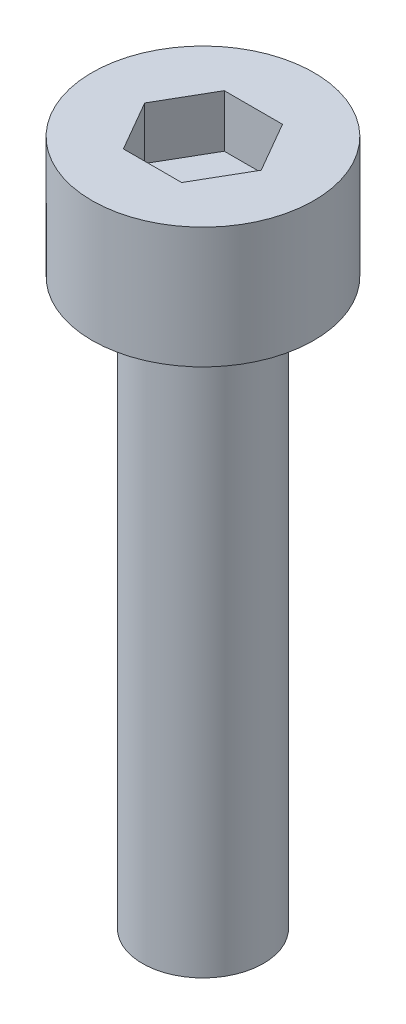
from build123d import *

# Parameters (mm, degrees)
SKETCH_1_R            = 2.75
EXTRUDE_248_DEPTH     = 3
CUT_EXTRUDE_378_DEPTH = 1.3
SKETCH_3_R            = 1.5
EXTRUDE_479_DEPTH     = 14


with BuildPart() as part:
    # 草图1 → Extrude 248 (new body)
    with BuildSketch(Plane(origin=(0, 0, 0), x_dir=(1, 0, 0), z_dir=(0, 1, 0))):
        Circle(SKETCH_1_R)
    extrude(amount=EXTRUDE_248_DEPTH)

    # 草图2 → Cut-Extrude 378 (cut)
    with BuildSketch(Plane(origin=(0, 3, 0), x_dir=(1, 0, 0), z_dir=(0, 1, 0))):
        Polygon((1.443375673, 0), (0.721687836, 1.25), (-0.721687836, 1.25), (-1.443375673, 0), (-0.721687836, -1.25), (0.721687836, -1.25), align=None)
    extrude(amount=-CUT_EXTRUDE_378_DEPTH, mode=Mode.SUBTRACT)

    # 草图3 → Extrude 479 (add)
    with BuildSketch(Plane.XZ):
        Circle(SKETCH_3_R)
    extrude(amount=EXTRUDE_479_DEPTH)


solid = part.part
